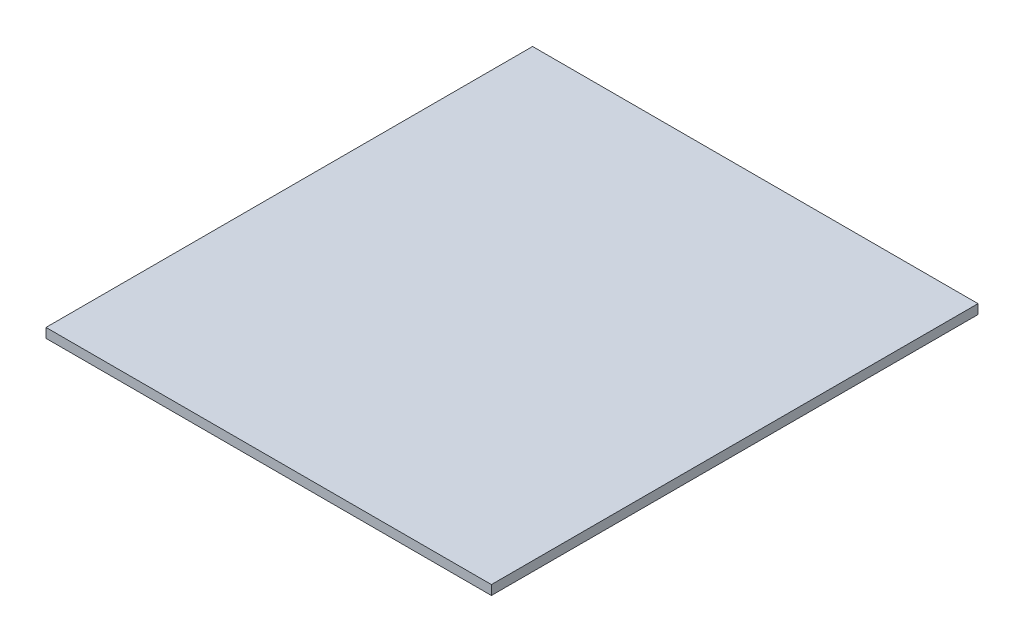
from build123d import *

# Parameters (mm, degrees)
SKETCH1_W           = 139.5
SKETCH1_H           = 152.4
BOSS_EXTRUDE1_DEPTH = 6.35
SKETCH2_W           = 139.5
SKETCH2_H           = 152.4
CUT_EXTRUDE1_DEPTH  = 3.375


with BuildPart() as part:
    # Sketch1 → Boss-Extrude1 (new body)
    with BuildSketch(Plane(origin=(0, 0, 0), x_dir=(1, 0, 0), z_dir=(0, 1, 0))):
        with Locations((69.75, 76.2)):
            Rectangle(SKETCH1_W, SKETCH1_H)
    extrude(amount=BOSS_EXTRUDE1_DEPTH)

    # Sketch2 → Cut-Extrude1 (cut)
    with BuildSketch(Plane(origin=(0, 6.35, 0), x_dir=(1, 0, 0), z_dir=(0, 1, 0))):
        with Locations((69.75, 76.2)):
            Rectangle(SKETCH2_W, SKETCH2_H)
    extrude(amount=-CUT_EXTRUDE1_DEPTH, mode=Mode.SUBTRACT)


solid = part.part
